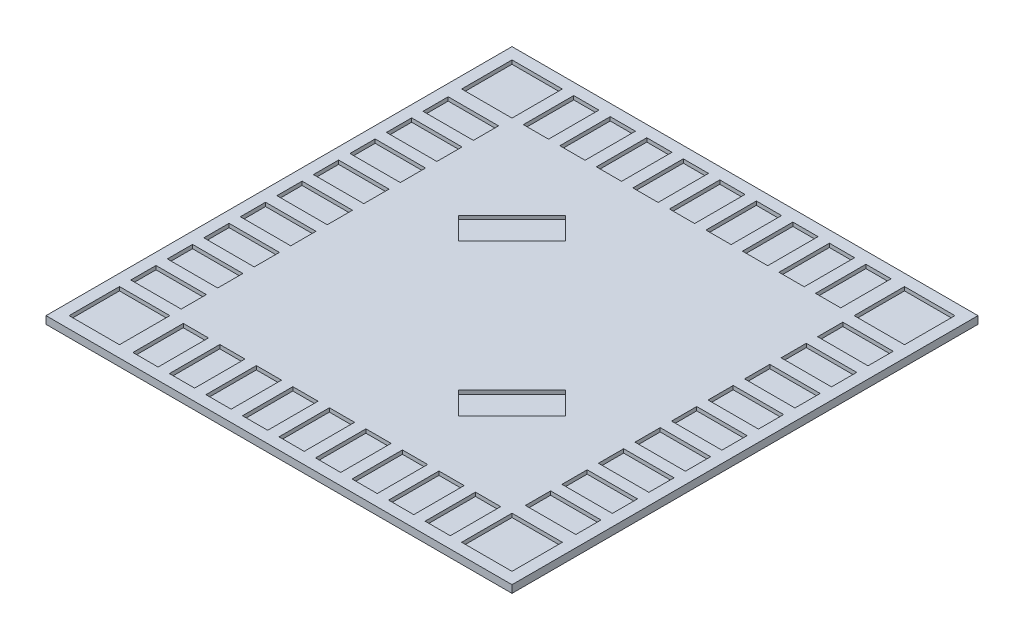
from build123d import *

# Parameters (mm, degrees)
SKETCH2_W           = 740
SKETCH2_H           = 740
SKETCH2_W_2         = 40
SKETCH2_H_2         = 80
SKETCH2_W_3         = 80
SKETCH2_H_3         = 40
BOSS_EXTRUDE1_DEPTH = 12
SKETCH2_4_W         = 40
SKETCH2_4_H         = 80
SKETCH2_4_W_2       = 80
SKETCH2_4_H_2       = 40
BOSS_EXTRUDE2_DEPTH = 6


with BuildPart() as part:
    # Sketch2 → Boss-Extrude1 (new body)
    with BuildSketch(Plane(origin=(0, 0, 0), x_dir=(1, 0, 0), z_dir=(0, 1, 0))):
        with Locations((-774.464507992, 184.557774434)):
            Rectangle(SKETCH2_W, SKETCH2_H)
        with Locations((-950.134507992, 496.227774434)):
            Rectangle(SKETCH2_W_2, SKETCH2_H_2, mode=Mode.SUBTRACT)
        with Locations((-1086.134507992, 496.227774434)):
            Rectangle(SKETCH2_W_3, SKETCH2_H_2, mode=Mode.SUBTRACT)
        with Locations((-1008.134507992, 496.227774434)):
            Rectangle(SKETCH2_W_2, SKETCH2_H_2, mode=Mode.SUBTRACT)
        with Locations((-892.134507992, 496.227774434)):
            Rectangle(SKETCH2_W_2, SKETCH2_H_2, mode=Mode.SUBTRACT)
        with Locations((-834.134507992, 496.227774434)):
            Rectangle(SKETCH2_W_2, SKETCH2_H_2, mode=Mode.SUBTRACT)
        with Locations((-776.134507992, 496.227774434)):
            Rectangle(SKETCH2_W_2, SKETCH2_H_2, mode=Mode.SUBTRACT)
        with Locations((-718.134507992, 496.227774434)):
            Rectangle(SKETCH2_W_2, SKETCH2_H_2, mode=Mode.SUBTRACT)
        with Locations((-660.134507992, 496.227774434)):
            Rectangle(SKETCH2_W_2, SKETCH2_H_2, mode=Mode.SUBTRACT)
        with Locations((-602.134507992, 496.227774434)):
            Rectangle(SKETCH2_W_2, SKETCH2_H_2, mode=Mode.SUBTRACT)
        with Locations((-544.134507992, 496.227774434)):
            Rectangle(SKETCH2_W_2, SKETCH2_H_2, mode=Mode.SUBTRACT)
        with Locations((-462.794507992, 360.227774434)):
            Rectangle(SKETCH2_W_3, SKETCH2_H_3, mode=Mode.SUBTRACT)
        with Locations((-462.794507992, 496.227774434)):
            Rectangle(SKETCH2_W_3, SKETCH2_H_2, mode=Mode.SUBTRACT)
        with Locations((-462.794507992, 418.227774434)):
            Rectangle(SKETCH2_W_3, SKETCH2_H_3, mode=Mode.SUBTRACT)
        with Locations((-462.794507992, 302.227774434)):
            Rectangle(SKETCH2_W_3, SKETCH2_H_3, mode=Mode.SUBTRACT)
        with Locations((-462.794507992, 244.227774434)):
            Rectangle(SKETCH2_W_3, SKETCH2_H_3, mode=Mode.SUBTRACT)
        with Locations((-462.794507992, 186.227774434)):
            Rectangle(SKETCH2_W_3, SKETCH2_H_3, mode=Mode.SUBTRACT)
        with Locations((-462.794507992, 128.227774434)):
            Rectangle(SKETCH2_W_3, SKETCH2_H_3, mode=Mode.SUBTRACT)
        with Locations((-462.794507992, 70.227774434)):
            Rectangle(SKETCH2_W_3, SKETCH2_H_3, mode=Mode.SUBTRACT)
        with Locations((-462.794507992, 12.227774434)):
            Rectangle(SKETCH2_W_3, SKETCH2_H_3, mode=Mode.SUBTRACT)
        with Locations((-462.794507992, -45.772225566)):
            Rectangle(SKETCH2_W_3, SKETCH2_H_3, mode=Mode.SUBTRACT)
        with Locations((-598.794507992, -127.112225566)):
            Rectangle(SKETCH2_W_2, SKETCH2_H_2, mode=Mode.SUBTRACT)
        with Locations((-462.794507992, -127.112225566)):
            Rectangle(SKETCH2_W_3, SKETCH2_H_2, mode=Mode.SUBTRACT)
        with Locations((-540.794507992, -127.112225566)):
            Rectangle(SKETCH2_W_2, SKETCH2_H_2, mode=Mode.SUBTRACT)
        with Locations((-656.794507992, -127.112225566)):
            Rectangle(SKETCH2_W_2, SKETCH2_H_2, mode=Mode.SUBTRACT)
        with Locations((-714.794507992, -127.112225566)):
            Rectangle(SKETCH2_W_2, SKETCH2_H_2, mode=Mode.SUBTRACT)
        with Locations((-772.794507992, -127.112225566)):
            Rectangle(SKETCH2_W_2, SKETCH2_H_2, mode=Mode.SUBTRACT)
        with Locations((-830.794507992, -127.112225566)):
            Rectangle(SKETCH2_W_2, SKETCH2_H_2, mode=Mode.SUBTRACT)
        with Locations((-888.794507992, -127.112225566)):
            Rectangle(SKETCH2_W_2, SKETCH2_H_2, mode=Mode.SUBTRACT)
        with Locations((-946.794507992, -127.112225566)):
            Rectangle(SKETCH2_W_2, SKETCH2_H_2, mode=Mode.SUBTRACT)
        with Locations((-1004.794507992, -127.112225566)):
            Rectangle(SKETCH2_W_2, SKETCH2_H_2, mode=Mode.SUBTRACT)
        with Locations((-1086.134507992, 8.887774434)):
            Rectangle(SKETCH2_W_3, SKETCH2_H_3, mode=Mode.SUBTRACT)
        with Locations((-1086.134507992, -127.112225566)):
            Rectangle(SKETCH2_W_3, SKETCH2_H_2, mode=Mode.SUBTRACT)
        with Locations((-1086.134507992, -49.112225566)):
            Rectangle(SKETCH2_W_3, SKETCH2_H_3, mode=Mode.SUBTRACT)
        with Locations((-1086.134507992, 66.887774434)):
            Rectangle(SKETCH2_W_3, SKETCH2_H_3, mode=Mode.SUBTRACT)
        with Locations((-1086.134507992, 124.887774434)):
            Rectangle(SKETCH2_W_3, SKETCH2_H_3, mode=Mode.SUBTRACT)
        with Locations((-1086.134507992, 182.887774434)):
            Rectangle(SKETCH2_W_3, SKETCH2_H_3, mode=Mode.SUBTRACT)
        with Locations((-1086.134507992, 240.887774434)):
            Rectangle(SKETCH2_W_3, SKETCH2_H_3, mode=Mode.SUBTRACT)
        with Locations((-1086.134507992, 298.887774434)):
            Rectangle(SKETCH2_W_3, SKETCH2_H_3, mode=Mode.SUBTRACT)
        with Locations((-1086.134507992, 356.887774434)):
            Rectangle(SKETCH2_W_3, SKETCH2_H_3, mode=Mode.SUBTRACT)
        with Locations((-1086.134507992, 414.887774434)):
            Rectangle(SKETCH2_W_3, SKETCH2_H_3, mode=Mode.SUBTRACT)
        Polygon((-919.421398135, 244.661850834), (-834.568584393, 329.514664577), (-869.923923452, 364.870003636), (-954.776737195, 280.017189894), align=None, mode=Mode.SUBTRACT)
        Polygon((-714.360431591, 39.60088429), (-629.507617849, 124.453698033), (-594.15227879, 89.098358973), (-679.005092532, 4.245545231), align=None, mode=Mode.SUBTRACT)
    extrude(amount=BOSS_EXTRUDE1_DEPTH)

    # Sketch2_4 → Boss-Extrude2 (add)
    with BuildSketch(Plane(origin=(0, 0, 0), x_dir=(1, 0, 0), z_dir=(0, 1, 0))):
        with Locations((-1008.134507992, 496.227774434)):
            Rectangle(SKETCH2_4_W, SKETCH2_4_H)
        with Locations((-950.134507992, 496.227774434)):
            Rectangle(SKETCH2_4_W, SKETCH2_4_H)
        with Locations((-892.134507992, 496.227774434)):
            Rectangle(SKETCH2_4_W, SKETCH2_4_H)
        with Locations((-834.134507992, 496.227774434)):
            Rectangle(SKETCH2_4_W, SKETCH2_4_H)
        with Locations((-718.134507992, 496.227774434)):
            Rectangle(SKETCH2_4_W, SKETCH2_4_H)
        with Locations((-602.134507992, 496.227774434)):
            Rectangle(SKETCH2_4_W, SKETCH2_4_H)
        with Locations((-544.134507992, 496.227774434)):
            Rectangle(SKETCH2_4_W, SKETCH2_4_H)
        with Locations((-462.794507992, 496.227774434)):
            Rectangle(SKETCH2_4_W_2, SKETCH2_4_H)
        with Locations((-462.794507992, 302.227774434)):
            Rectangle(SKETCH2_4_W_2, SKETCH2_4_H_2)
        with Locations((-462.794507992, 244.227774434)):
            Rectangle(SKETCH2_4_W_2, SKETCH2_4_H_2)
        with Locations((-462.794507992, 186.227774434)):
            Rectangle(SKETCH2_4_W_2, SKETCH2_4_H_2)
        with Locations((-462.794507992, 128.227774434)):
            Rectangle(SKETCH2_4_W_2, SKETCH2_4_H_2)
        with Locations((-462.794507992, 70.227774434)):
            Rectangle(SKETCH2_4_W_2, SKETCH2_4_H_2)
        with Locations((-462.794507992, 12.227774434)):
            Rectangle(SKETCH2_4_W_2, SKETCH2_4_H_2)
        with Locations((-462.794507992, -127.112225566)):
            Rectangle(SKETCH2_4_W_2, SKETCH2_4_H)
        with Locations((-540.794507992, -127.112225566)):
            Rectangle(SKETCH2_4_W, SKETCH2_4_H)
        with Locations((-598.794507992, -127.112225566)):
            Rectangle(SKETCH2_4_W, SKETCH2_4_H)
        with Locations((-656.794507992, -127.112225566)):
            Rectangle(SKETCH2_4_W, SKETCH2_4_H)
        with Locations((-714.794507992, -127.112225566)):
            Rectangle(SKETCH2_4_W, SKETCH2_4_H)
        with Locations((-772.794507992, -127.112225566)):
            Rectangle(SKETCH2_4_W, SKETCH2_4_H)
        with Locations((-830.794507992, -127.112225566)):
            Rectangle(SKETCH2_4_W, SKETCH2_4_H)
        with Locations((-888.794507992, -127.112225566)):
            Rectangle(SKETCH2_4_W, SKETCH2_4_H)
        with Locations((-946.794507992, -127.112225566)):
            Rectangle(SKETCH2_4_W, SKETCH2_4_H)
        with Locations((-1004.794507992, -127.112225566)):
            Rectangle(SKETCH2_4_W, SKETCH2_4_H)
        with Locations((-1086.134507992, -127.112225566)):
            Rectangle(SKETCH2_4_W_2, SKETCH2_4_H)
        with Locations((-1086.134507992, -49.112225566)):
            Rectangle(SKETCH2_4_W_2, SKETCH2_4_H_2)
        with Locations((-1086.134507992, 8.887774434)):
            Rectangle(SKETCH2_4_W_2, SKETCH2_4_H_2)
        with Locations((-1086.134507992, 66.887774434)):
            Rectangle(SKETCH2_4_W_2, SKETCH2_4_H_2)
        with Locations((-1086.134507992, 124.887774434)):
            Rectangle(SKETCH2_4_W_2, SKETCH2_4_H_2)
        with Locations((-1086.134507992, 182.887774434)):
            Rectangle(SKETCH2_4_W_2, SKETCH2_4_H_2)
        with Locations((-1086.134507992, 240.887774434)):
            Rectangle(SKETCH2_4_W_2, SKETCH2_4_H_2)
        with Locations((-1086.134507992, 298.887774434)):
            Rectangle(SKETCH2_4_W_2, SKETCH2_4_H_2)
        with Locations((-1086.134507992, 356.887774434)):
            Rectangle(SKETCH2_4_W_2, SKETCH2_4_H_2)
        with Locations((-1086.134507992, 414.887774434)):
            Rectangle(SKETCH2_4_W_2, SKETCH2_4_H_2)
        Polygon((-954.776737195, 280.017189894), (-869.923923452, 364.870003636), (-834.568584393, 329.514664577), (-919.421398135, 244.661850834), align=None)
        Polygon((-714.360431591, 39.60088429), (-679.005092532, 4.245545231), (-594.15227879, 89.098358973), (-629.507617849, 124.453698033), align=None)
        with Locations((-1086.134507992, 496.227774434)):
            Rectangle(SKETCH2_4_W_2, SKETCH2_4_H)
        with Locations((-776.134507992, 496.227774434)):
            Rectangle(SKETCH2_4_W, SKETCH2_4_H)
        with Locations((-660.134507992, 496.227774434)):
            Rectangle(SKETCH2_4_W, SKETCH2_4_H)
        with Locations((-462.794507992, 418.227774434)):
            Rectangle(SKETCH2_4_W_2, SKETCH2_4_H_2)
        with Locations((-462.794507992, 360.227774434)):
            Rectangle(SKETCH2_4_W_2, SKETCH2_4_H_2)
        with Locations((-462.794507992, -45.772225566)):
            Rectangle(SKETCH2_4_W_2, SKETCH2_4_H_2)
    extrude(amount=BOSS_EXTRUDE2_DEPTH)


solid = part.part
